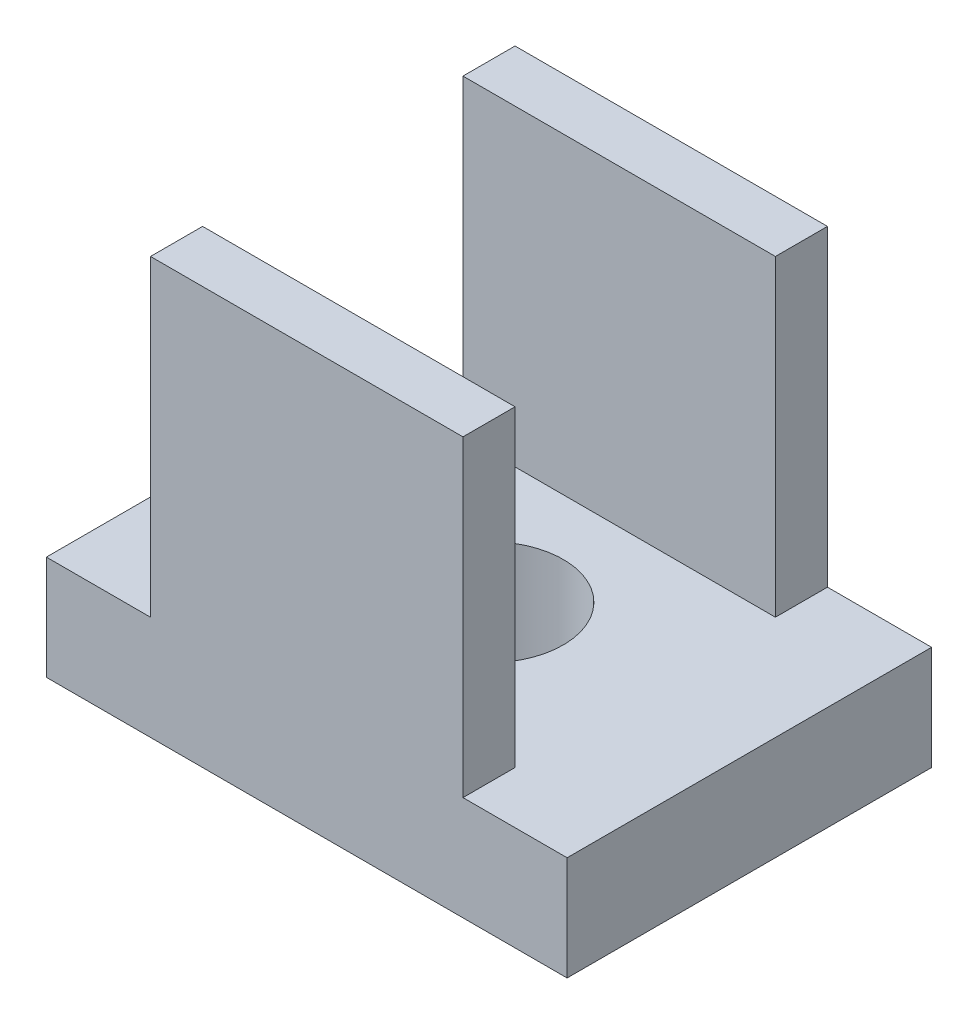
from build123d import *

# Parameters (mm, degrees)
SKETCH1_W           = 10
SKETCH1_H           = 7
BOSS_EXTRUDE1_DEPTH = 2
SKETCH2_R           = 1.425
CUT_EXTRUDE1_DEPTH  = 3
SKETCH3_W           = 6
SKETCH3_H           = 1
BOSS_EXTRUDE2_DEPTH = 6


with BuildPart() as part:
    # Sketch1 → Boss-Extrude1 (new body)
    with BuildSketch(Plane(origin=(0, 0, 0), x_dir=(1, 0, 0), z_dir=(0, 1, 0))):
        Rectangle(SKETCH1_W, SKETCH1_H)
    extrude(amount=BOSS_EXTRUDE1_DEPTH)

    # Sketch2 → Cut-Extrude1 (cut, through all)
    with BuildSketch(Plane(origin=(0, 2, 0), x_dir=(1, 0, 0), z_dir=(0, 1, 0))):
        Circle(SKETCH2_R)
    extrude(amount=-CUT_EXTRUDE1_DEPTH, mode=Mode.SUBTRACT)

    # Sketch3 → Boss-Extrude2 (add)
    with BuildSketch(Plane(origin=(0, 2, 0), x_dir=(1, 0, 0), z_dir=(0, 1, 0))):
        with Locations((0, 3)):
            Rectangle(SKETCH3_W, SKETCH3_H)
    boss_extrude2 = extrude(amount=BOSS_EXTRUDE2_DEPTH)

    # Mirror1: Boss-Extrude2 across plane
    add(boss_extrude2.mirror(Plane.XY))


solid = part.part
